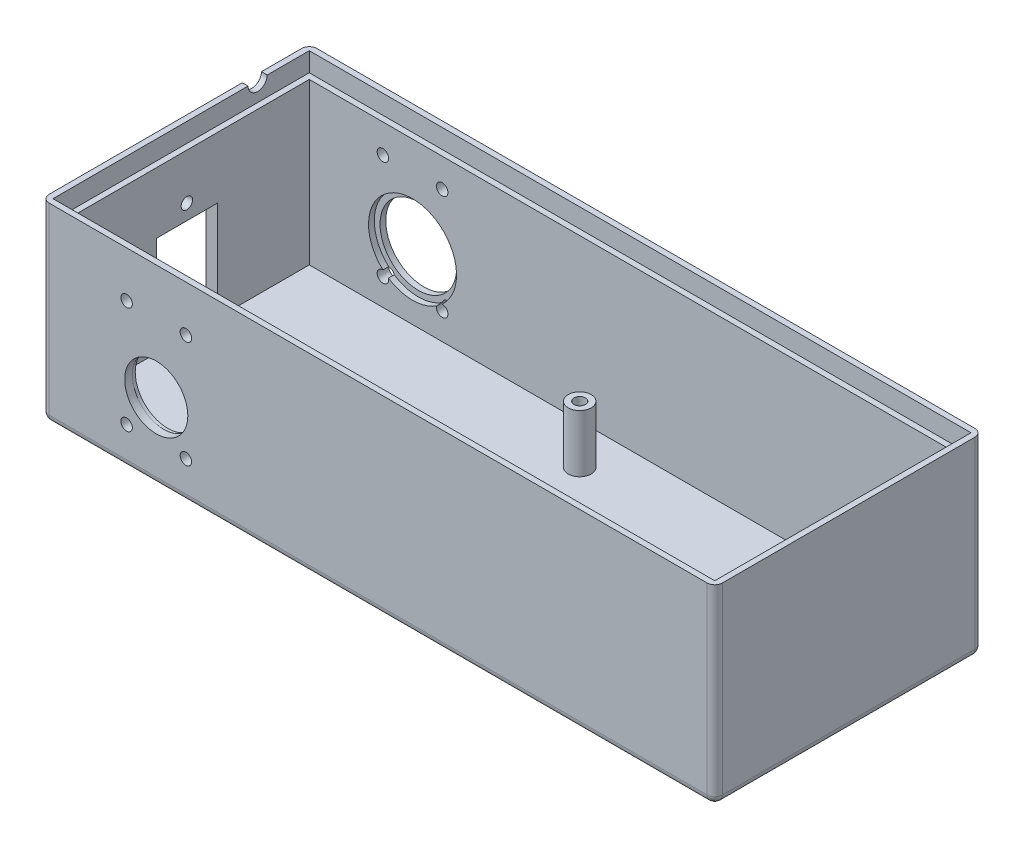
from build123d import *

# Parameters (mm, degrees)
SKETCH1_W           = 176
SKETCH1_H           = 70
BOSS_EXTRUDE1_DEPTH = 50
SKETCH2_W           = 170
SKETCH2_H           = 64
CUT_EXTRUDE1_DEPTH  = 47
SKETCH3_W           = 173
SKETCH3_H           = 67
CUT_EXTRUDE2_DEPTH  = 5
SKETCH4_R           = 3
SKETCH4_R_2         = 1.5
BOSS_EXTRUDE2_DEPTH = 15
CUT_EXTRUDE3_REACH  = 72
SKETCH5_R           = 10
SKETCH5_R_2         = 1.5
SKETCH6_R           = 11.5
CUT_EXTRUDE4_DEPTH  = 1.5
CUT_EXTRUDE5_REACH  = 72
SKETCH7_R           = 8.25
SKETCH7_R_2         = 1.5
SKETCH8_R           = 8.5
CUT_EXTRUDE6_DEPTH  = 1
FILLET1_R           = 2
CUT_EXTRUDE7_REACH  = 178
SKETCH9_R           = 1.5
SKETCH9_R_2         = 1
SKETCH9_W           = 16
SKETCH9_H           = 21
CUT_EXTRUDE8_REACH  = 178
SKETCH10_R          = 2.5


with BuildPart() as part:
    # Sketch1 → Boss-Extrude1 (new body)
    with BuildSketch(Plane(origin=(0, 0, 0), x_dir=(1, 0, 0), z_dir=(0, 1, 0))):
        Rectangle(SKETCH1_W, SKETCH1_H)
    extrude(amount=BOSS_EXTRUDE1_DEPTH)

    # Sketch2 → Cut-Extrude1 (cut)
    with BuildSketch(Plane(origin=(0, 50, 0), x_dir=(1, 0, 0), z_dir=(0, 1, 0))):
        Rectangle(SKETCH2_W, SKETCH2_H)
    extrude(amount=-CUT_EXTRUDE1_DEPTH, mode=Mode.SUBTRACT)

    # Sketch3 → Cut-Extrude2 (cut)
    with BuildSketch(Plane(origin=(0, 50, 0), x_dir=(1, 0, 0), z_dir=(0, 1, 0))):
        Rectangle(SKETCH3_W, SKETCH3_H)
    extrude(amount=-CUT_EXTRUDE2_DEPTH, mode=Mode.SUBTRACT)

    # Sketch4 → Boss-Extrude2 (add)
    with BuildSketch(Plane(origin=(0, 3, 0), x_dir=(1, 0, 0), z_dir=(0, 1, 0))):
        with Locations((-4.8, -27)):
            Circle(SKETCH4_R)
        with Locations((-4.8, -27)):
            Circle(SKETCH4_R_2, mode=Mode.SUBTRACT)
        with Locations((78, -27)):
            Circle(SKETCH4_R)
        with Locations((78, -27)):
            Circle(SKETCH4_R_2, mode=Mode.SUBTRACT)
        with Locations((71.2, 21.5)):
            Circle(SKETCH4_R)
        with Locations((71.2, 21.5)):
            Circle(SKETCH4_R_2, mode=Mode.SUBTRACT)
        with Locations((-3.8, 21.5)):
            Circle(SKETCH4_R)
        with Locations((-3.8, 21.5)):
            Circle(SKETCH4_R_2, mode=Mode.SUBTRACT)
    extrude(amount=BOSS_EXTRUDE2_DEPTH)

    # Sketch5 → Cut-Extrude3 (cut, up to next)
    with BuildSketch(Plane(origin=(0, 0, -35), x_dir=(-1, 0, 0), z_dir=(0, 0, -1)), mode=Mode.PRIVATE) as cut_extrude3_sk1:
        with Locations((58, 20)):
            Circle(SKETCH5_R)
    cut_extrude3_tool1 = extrude(cut_extrude3_sk1.sketch, amount=-CUT_EXTRUDE3_REACH, mode=Mode.PRIVATE) & part.part
    add(cut_extrude3_tool1.solids().sort_by_distance((-58, 20, -35))[0], mode=Mode.SUBTRACT)
    # Sketch5 → Cut-Extrude3 (cut, up to next)
    with BuildSketch(Plane(origin=(0, 0, -35), x_dir=(-1, 0, 0), z_dir=(0, 0, -1)), mode=Mode.PRIVATE) as cut_extrude3_sk2:
        with Locations((65.75, 37.5)):
            Circle(SKETCH5_R_2)
    cut_extrude3_tool2 = extrude(cut_extrude3_sk2.sketch, amount=-CUT_EXTRUDE3_REACH, mode=Mode.PRIVATE) & part.part
    add(cut_extrude3_tool2.solids().sort_by_distance((-65.75, 37.5, -35))[0], mode=Mode.SUBTRACT)
    # Sketch5 → Cut-Extrude3 (cut, up to next)
    with BuildSketch(Plane(origin=(0, 0, -35), x_dir=(-1, 0, 0), z_dir=(0, 0, -1)), mode=Mode.PRIVATE) as cut_extrude3_sk3:
        with Locations((50.25, 37.5)):
            Circle(SKETCH5_R_2)
    cut_extrude3_tool3 = extrude(cut_extrude3_sk3.sketch, amount=-CUT_EXTRUDE3_REACH, mode=Mode.PRIVATE) & part.part
    add(cut_extrude3_tool3.solids().sort_by_distance((-50.25, 37.5, -35))[0], mode=Mode.SUBTRACT)
    # Sketch5 → Cut-Extrude3 (cut, up to next)
    with BuildSketch(Plane(origin=(0, 0, -35), x_dir=(-1, 0, 0), z_dir=(0, 0, -1)), mode=Mode.PRIVATE) as cut_extrude3_sk4:
        with Locations((50.25, 10)):
            Circle(SKETCH5_R_2)
    cut_extrude3_tool4 = extrude(cut_extrude3_sk4.sketch, amount=-CUT_EXTRUDE3_REACH, mode=Mode.PRIVATE) & part.part
    add(cut_extrude3_tool4.solids().sort_by_distance((-50.25, 10, -35))[0], mode=Mode.SUBTRACT)
    # Sketch5 → Cut-Extrude3 (cut, up to next)
    with BuildSketch(Plane(origin=(0, 0, -35), x_dir=(-1, 0, 0), z_dir=(0, 0, -1)), mode=Mode.PRIVATE) as cut_extrude3_sk5:
        with Locations((65.75, 10)):
            Circle(SKETCH5_R_2)
    cut_extrude3_tool5 = extrude(cut_extrude3_sk5.sketch, amount=-CUT_EXTRUDE3_REACH, mode=Mode.PRIVATE) & part.part
    add(cut_extrude3_tool5.solids().sort_by_distance((-65.75, 10, -35))[0], mode=Mode.SUBTRACT)

    # Sketch6 → Cut-Extrude4 (cut)
    with BuildSketch(Plane.XY.offset(-32)):
        with Locations((-58, 20)):
            Circle(SKETCH6_R)
    extrude(amount=-CUT_EXTRUDE4_DEPTH, mode=Mode.SUBTRACT)

    # Sketch7 → Cut-Extrude5 (cut, up to next)
    with BuildSketch(Plane.XY.offset(35), mode=Mode.PRIVATE) as cut_extrude5_sk1:
        with Locations((-58, 20)):
            Circle(SKETCH7_R)
    cut_extrude5_tool1 = extrude(cut_extrude5_sk1.sketch, amount=-CUT_EXTRUDE5_REACH, mode=Mode.PRIVATE) & part.part
    add(cut_extrude5_tool1.solids().sort_by_distance((-58, 20, 35))[0], mode=Mode.SUBTRACT)
    # Sketch7 → Cut-Extrude5 (cut, up to next)
    with BuildSketch(Plane.XY.offset(35), mode=Mode.PRIVATE) as cut_extrude5_sk2:
        with Locations((-65.75, 38)):
            Circle(SKETCH7_R_2)
    cut_extrude5_tool2 = extrude(cut_extrude5_sk2.sketch, amount=-CUT_EXTRUDE5_REACH, mode=Mode.PRIVATE) & part.part
    add(cut_extrude5_tool2.solids().sort_by_distance((-65.75, 38, 35))[0], mode=Mode.SUBTRACT)
    # Sketch7 → Cut-Extrude5 (cut, up to next)
    with BuildSketch(Plane.XY.offset(35), mode=Mode.PRIVATE) as cut_extrude5_sk3:
        with Locations((-50.25, 38)):
            Circle(SKETCH7_R_2)
    cut_extrude5_tool3 = extrude(cut_extrude5_sk3.sketch, amount=-CUT_EXTRUDE5_REACH, mode=Mode.PRIVATE) & part.part
    add(cut_extrude5_tool3.solids().sort_by_distance((-50.25, 38, 35))[0], mode=Mode.SUBTRACT)
    # Sketch7 → Cut-Extrude5 (cut, up to next)
    with BuildSketch(Plane.XY.offset(35), mode=Mode.PRIVATE) as cut_extrude5_sk4:
        with Locations((-65.75, 10)):
            Circle(SKETCH7_R_2)
    cut_extrude5_tool4 = extrude(cut_extrude5_sk4.sketch, amount=-CUT_EXTRUDE5_REACH, mode=Mode.PRIVATE) & part.part
    add(cut_extrude5_tool4.solids().sort_by_distance((-65.75, 10, 35))[0], mode=Mode.SUBTRACT)
    # Sketch7 → Cut-Extrude5 (cut, up to next)
    with BuildSketch(Plane.XY.offset(35), mode=Mode.PRIVATE) as cut_extrude5_sk5:
        with Locations((-50.25, 10)):
            Circle(SKETCH7_R_2)
    cut_extrude5_tool5 = extrude(cut_extrude5_sk5.sketch, amount=-CUT_EXTRUDE5_REACH, mode=Mode.PRIVATE) & part.part
    add(cut_extrude5_tool5.solids().sort_by_distance((-50.25, 10, 35))[0], mode=Mode.SUBTRACT)

    # Sketch8 → Cut-Extrude6 (cut)
    with BuildSketch(Plane(origin=(0, 0, 32), x_dir=(-1, 0, 0), z_dir=(0, 0, -1))):
        with Locations((58, 20)):
            Circle(SKETCH8_R)
    extrude(amount=-CUT_EXTRUDE6_DEPTH, mode=Mode.SUBTRACT)

    # Fillet1
    fillet1_edges = [part.edges().sort_by_distance(p)[0] for p in [
        (0, 0, -35),
        (88, 0, 0),
        (0, 0, 35),
        (-88, 0, 0),
        (-88, 25, -35),
        (88, 25, -35),
        (88, 25, 35),
        (-88, 25, 35),
    ]]
    fillet(fillet1_edges, radius=FILLET1_R)

    # Sketch9 → Cut-Extrude7 (cut, up to next)
    with BuildSketch(Plane.ZY.offset(88), mode=Mode.PRIVATE) as cut_extrude7_sk1:
        with Locations((0, 33)):
            Circle(SKETCH9_R)
    cut_extrude7_tool1 = extrude(cut_extrude7_sk1.sketch, amount=-CUT_EXTRUDE7_REACH, mode=Mode.PRIVATE) & part.part
    add(cut_extrude7_tool1.solids().sort_by_distance((-88, 33, 0))[0], mode=Mode.SUBTRACT)
    # Sketch9 → Cut-Extrude7 (cut, up to next)
    with BuildSketch(Plane.ZY.offset(88), mode=Mode.PRIVATE) as cut_extrude7_sk2:
        with Locations((0, 6)):
            Circle(SKETCH9_R_2)
    cut_extrude7_tool2 = extrude(cut_extrude7_sk2.sketch, amount=-CUT_EXTRUDE7_REACH, mode=Mode.PRIVATE) & part.part
    add(cut_extrude7_tool2.solids().sort_by_distance((-88, 6, 0))[0], mode=Mode.SUBTRACT)
    # Sketch9 → Cut-Extrude7 (cut, up to next)
    with BuildSketch(Plane.ZY.offset(88), mode=Mode.PRIVATE) as cut_extrude7_sk3:
        with Locations((0, 18.5)):
            Rectangle(SKETCH9_W, SKETCH9_H)
    cut_extrude7_tool3 = extrude(cut_extrude7_sk3.sketch, amount=-CUT_EXTRUDE7_REACH, mode=Mode.PRIVATE) & part.part
    add(cut_extrude7_tool3.solids().sort_by_distance((-88, 18.5, 0))[0], mode=Mode.SUBTRACT)

    # Sketch10 → Cut-Extrude8 (cut, up to next)
    with BuildSketch(Plane.ZY.offset(88), mode=Mode.PRIVATE) as cut_extrude8_sk1:
        with Locations((-20, 50)):
            Circle(SKETCH10_R)
    cut_extrude8_tool1 = extrude(cut_extrude8_sk1.sketch, amount=-CUT_EXTRUDE8_REACH, mode=Mode.PRIVATE) & part.part
    add(cut_extrude8_tool1.solids().sort_by_distance((-88, 50, -20))[0], mode=Mode.SUBTRACT)


solid = part.part
